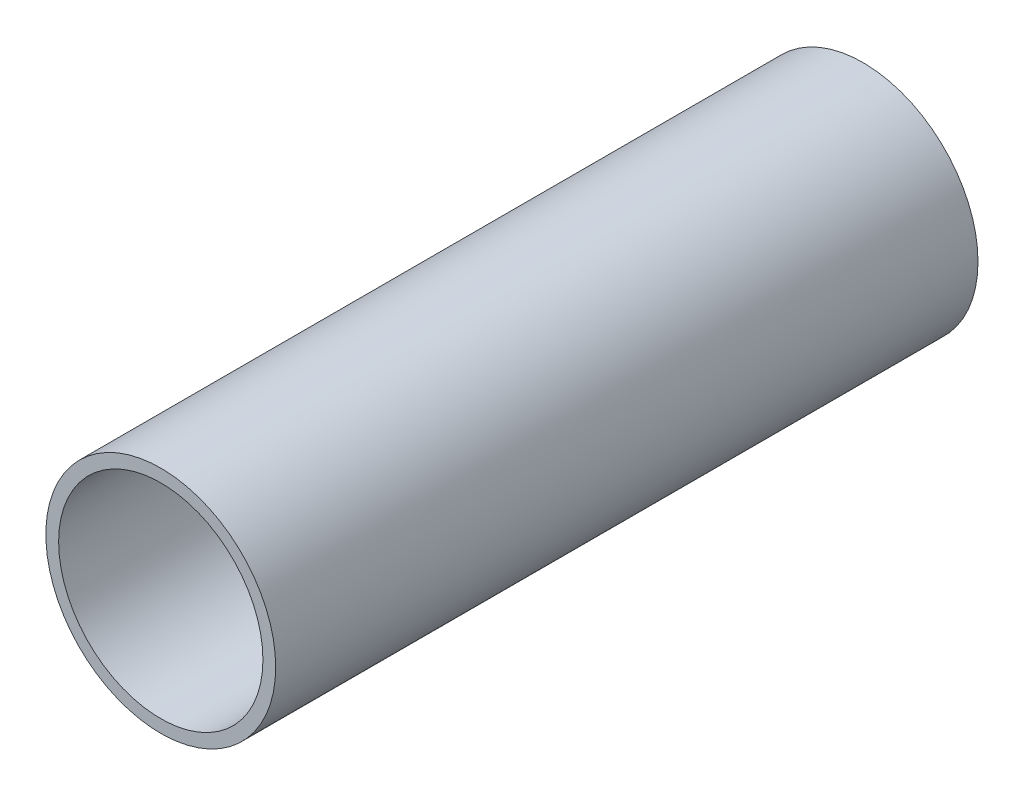
from build123d import *

# Parameters (mm, degrees)
SKETCH1_R           = 18
SKETCH1_R_2         = 16
BOSS_EXTRUDE1_DEPTH = 110


with BuildPart() as part:
    # Sketch1 → Boss-Extrude1 (new body)
    with BuildSketch(Plane.XY):
        Circle(SKETCH1_R)
        Circle(SKETCH1_R_2, mode=Mode.SUBTRACT)
    extrude(amount=BOSS_EXTRUDE1_DEPTH)


solid = part.part
